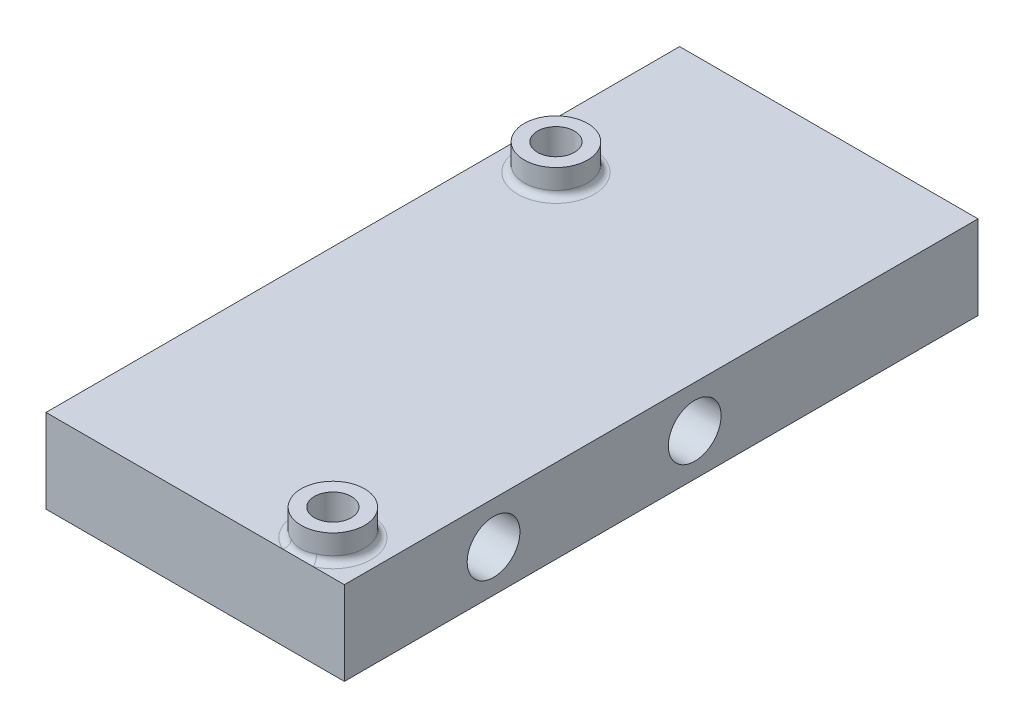
from build123d import *

# Parameters (mm, degrees)
SKETCH1_W           = 22.606
SKETCH1_H           = 48.006
SKETCH1_R           = 1.4
BOSS_EXTRUDE1_DEPTH = 6.35
SKETCH2_R           = 2
CUT_EXTRUDE1_DEPTH  = 23.606
SKETCH3_R           = 2.4
SKETCH3_R_2         = 1.4
BOSS_EXTRUDE2_DEPTH = 2
FILLET1_R           = 0.5


with BuildPart() as part:
    # Sketch1 → Boss-Extrude1 (new body)
    with BuildSketch(Plane(origin=(0, 0, 0), x_dir=(1, 0, 0), z_dir=(0, 1, 0))):
        with Locations((11.43, 24.13)):
            Rectangle(SKETCH1_W, SKETCH1_H)
        with Locations((3.6835, 35.20575)):
            Circle(SKETCH1_R, mode=Mode.SUBTRACT)
        with Locations((19.2073, 2.78275)):
            Circle(SKETCH1_R, mode=Mode.SUBTRACT)
    extrude(amount=BOSS_EXTRUDE1_DEPTH)

    # Sketch2 → Cut-Extrude1 (cut, through all)
    with BuildSketch(Plane.ZY.offset(-0.127)):
        with Locations((-26.67, 3.175)):
            Circle(SKETCH2_R)
        with Locations((-11.43, 3.175)):
            Circle(SKETCH2_R)
    extrude(amount=-CUT_EXTRUDE1_DEPTH, mode=Mode.SUBTRACT)

    # Sketch3 → Boss-Extrude2 (add)
    with BuildSketch(Plane(origin=(0, 6.35, 0), x_dir=(1, 0, 0), z_dir=(0, 1, 0))):
        with Locations((3.6835, 35.20575)):
            Circle(SKETCH3_R)
        with Locations((3.6835, 35.20575)):
            Circle(SKETCH3_R_2, mode=Mode.SUBTRACT)
        with Locations((19.2073, 2.78275)):
            Circle(SKETCH3_R)
        with Locations((19.2073, 2.78275)):
            Circle(SKETCH3_R_2, mode=Mode.SUBTRACT)
    extrude(amount=BOSS_EXTRUDE2_DEPTH)

    # Fillet1
    fillet1_edges = [part.edges().sort_by_distance(p)[0] for p in [
        (1.2835, 6.35, -35.20575),
        (16.8073, 6.35, -2.78275),
    ]]
    fillet(fillet1_edges, radius=FILLET1_R)


solid = part.part
